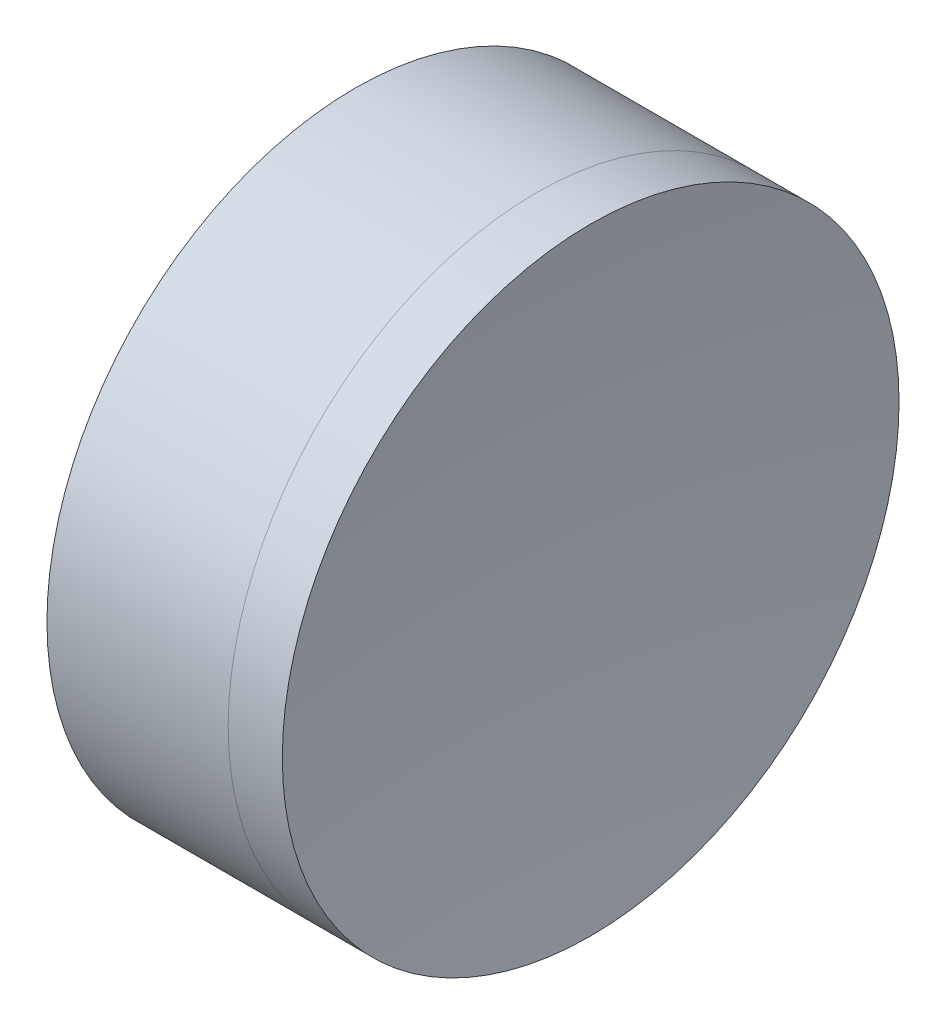
from build123d import *


with BuildPart() as part:
    # 草图1 one side → 旋转1 (revolve)
    with BuildSketch(Plane(origin=(0, 0, 0), x_dir=(1, 0, 0), z_dir=(0, 1, 0)), mode=Mode.PRIVATE) as revolve_1_sk:
        with BuildLine():
            Line((258.868142477, 20), (247.114403729, 20))
            ThreePointArc((247.114403729, 20), (249.67277371, 10.14509842), (250.533773229, 0))
            Line((250.533773229, 0), (254.533773229, 0))
            ThreePointArc((254.533773229, 0), (255.629798488, 10.232140011), (258.868142477, 20))
        make_face()
    revolve(revolve_1_sk.sketch.rotate(Axis((-0.816062176, 0, 0), (1, 0, 0)), 180), axis=Axis((-0.816062176, 0, 0), (1, 0, 0)))  # turned: the seam where the file's is


with BuildPart() as body_2:
    # 草图2 one side → 旋转3 (revolve)
    with BuildSketch(Plane(origin=(0, 0, 0), x_dir=(1, 0, 0), z_dir=(0, 1, 0))):
        with BuildLine():
            Line((262.382156238, 20), (258.868142477, 20))
            ThreePointArc((258.868142477, 20), (255.629798488, 10.232140011), (254.533773229, 0))
            Line((254.533773229, 0), (261.033773229, 0))
            ThreePointArc((261.033773229, 0), (261.371251167, 10.022700943), (262.382156238, 20))
        make_face()
    revolve(axis=Axis((247.114403729, 0, 0), (1, 0, 0)))


solid = Compound([part.part, body_2.part])
